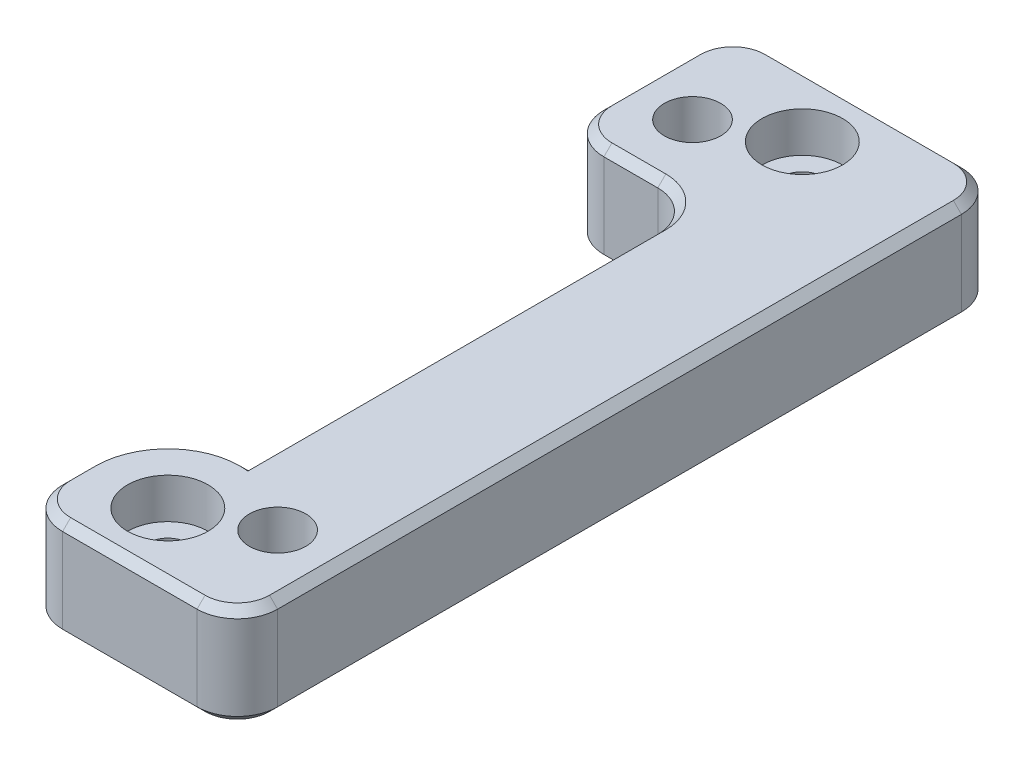
from build123d import *

# Parameters (mm, degrees)
SKETCH2_W           = 13.35
SKETCH2_H           = 37.95
SKETCH2_R           = 1.4
SKETCH2_R_2         = 1
BOSS_EXTRUDE1_DEPTH = 5
SKETCH3_R           = 2
CUT_EXTRUDE1_DEPTH  = 2
CUT_EXTRUDE2_DEPTH  = 6
FILLET1_R           = 2
CHAMFER1_SIZE       = 0.4


with BuildPart() as part:
    # Sketch2 → Boss-Extrude1 (new body)
    with BuildSketch(Plane(origin=(0, 0, 0), x_dir=(1, 0, 0), z_dir=(0, 1, 0))):
        Rectangle(SKETCH2_W, SKETCH2_H)
        with Locations((-3.675, 13.975)):
            Circle(SKETCH2_R, mode=Mode.SUBTRACT)
        with Locations((3.675, -13.975)):
            Circle(SKETCH2_R, mode=Mode.SUBTRACT)
        with Locations((0, 15.75)):
            Circle(SKETCH2_R_2, mode=Mode.SUBTRACT)
        with Locations((0, -15.75)):
            Circle(SKETCH2_R_2, mode=Mode.SUBTRACT)
    extrude(amount=BOSS_EXTRUDE1_DEPTH)

    # Sketch3 → Cut-Extrude1 (cut)
    with BuildSketch(Plane(origin=(0, 5, 0), x_dir=(1, 0, 0), z_dir=(0, 1, 0))):
        with Locations((0, 15.75)):
            Circle(SKETCH3_R)
        with Locations((0, -15.75)):
            Circle(SKETCH3_R)
    extrude(amount=-CUT_EXTRUDE1_DEPTH, mode=Mode.SUBTRACT)

    # Sketch4 → Cut-Extrude2 (cut, through all)
    with BuildSketch(Plane(origin=(0, 5, 0), x_dir=(1, 0, 0), z_dir=(0, 1, 0))):
        with BuildLine():
            Line((-6.675, 10.575), (-2, 10.575))
            ThreePointArc((-2, 10.575), (-0.585786438, 9.989213562), (0, 8.575))
            Line((0, 8.575), (0, -11.75))
            ThreePointArc((0, -11.75), (-2.828427125, -12.921572875), (-4, -15.75))
            Line((-4, -15.75), (-4, -18.975))
            Line((-4, -18.975), (-6.675, -18.975))
            Line((-6.675, -18.975), (-6.675, 10.575))
        make_face()
    extrude(amount=-CUT_EXTRUDE2_DEPTH, mode=Mode.SUBTRACT)

    # Fillet1
    fillet1_edges = [part.edges().sort_by_distance(p)[0] for p in [
        (-6.675, 2.5, -10.575),
        (-4, 2.5, 18.975),
        (-6.675, 2.5, -18.975),
        (6.675, 2.5, -18.975),
        (6.675, 2.5, 18.975),
    ]]
    fillet(fillet1_edges, radius=FILLET1_R)

    # Chamfer1
    chamfer1_edges = [part.edges().sort_by_distance(p)[0] for p in [
        (-3.3375, 0, -10.575),
        (-0.585786438, 0, -9.989213562),
        (0, 0, 1.5875),
        (-2.828427125, 0, 12.921572875),
        (-2.828427125, 5, 12.921572875),
        (0, 5, 1.5875),
        (-0.585786438, 5, -9.989213562),
        (-3.3375, 5, -10.575),
        (-6.675, 0, -14.775),
        (-6.675, 5, -14.775),
        (-4, 5, 16.3625),
        (1.3375, 5, 18.975),
        (6.675, 5, 0),
        (0, 5, -18.975),
        (-3.414213562, 5, 18.389213562),
        (6.089213562, 5, 18.389213562),
        (6.089213562, 5, -18.389213562),
        (-6.089213562, 5, -18.389213562),
        (-6.089213562, 5, -11.160786438),
        (0, 0, -18.975),
        (6.675, 0, 0),
        (1.3375, 0, 18.975),
        (-4, 0, 16.3625),
        (-3.414213562, 0, 18.389213562),
        (6.089213562, 0, 18.389213562),
        (6.089213562, 0, -18.389213562),
        (-6.089213562, 0, -18.389213562),
        (-6.089213562, 0, -11.160786438),
    ]]
    chamfer(chamfer1_edges, length=CHAMFER1_SIZE)


solid = part.part
